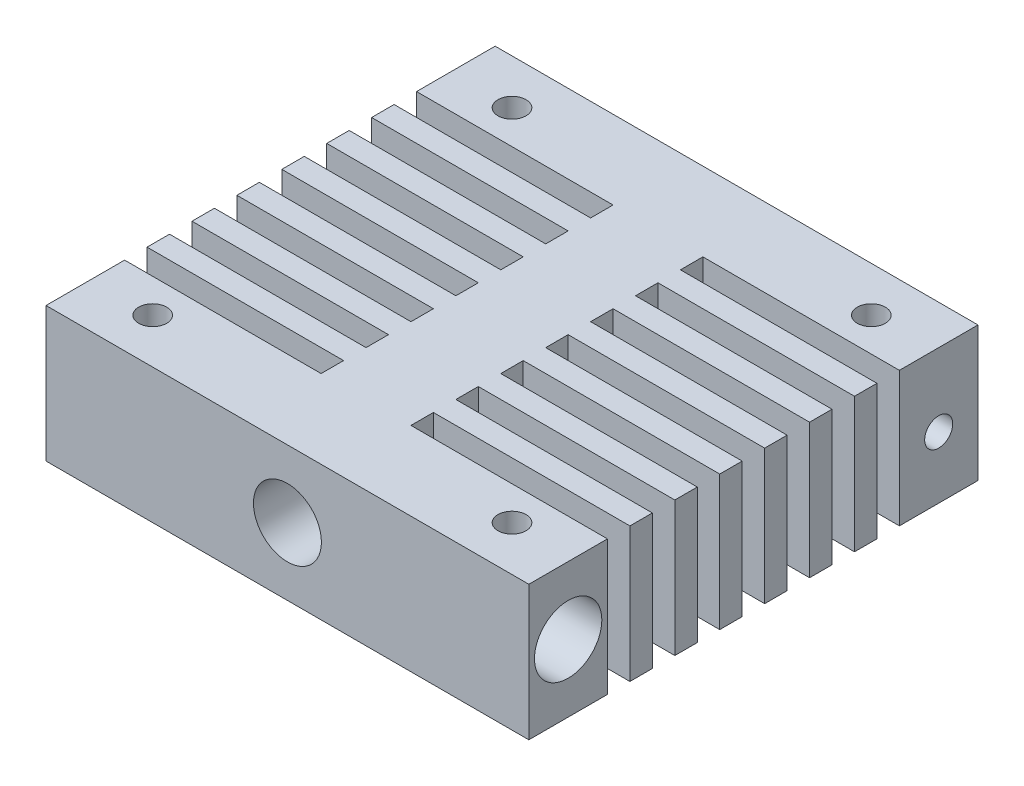
from build123d import *

# Parameters (mm, degrees)
SKETCH_1_W              = 43
SKETCH_1_H              = 40
EXTRUDE_1_DEPTH         = 2
SKETCH_3_W              = 43
SKETCH_3_H              = 40
EXTRUDE_3_DEPTH         = 10
SKETCH_4_R              = 3.025
CUT_EXTRUDE_1_DEPTH     = 20
CUT_EXTRUDE_2_REACH     = 48.971
SKETCH_5_R              = 2.025
HOLE_WIZARD_M6_1_D      = 5
HOLE_WIZARD_M6_1_DEPTH  = 8
SKETCH_8_W              = 17.5
SKETCH_8_H              = 2
CUT_EXTRUDE_3_DEPTH     = 12
HOLE_WIZARD_M3_1_D      = 2.5
HOLE_WIZARD_M3_2_D      = 2.5
HOLE_WIZARD_M3_2_DEPTH  = 4
HOLE_WIZARD_M3_3_D      = 2.5
HOLE_WIZARD_M3_3_DEPTH  = 4
SKETCH_16_R             = 3
CUT_EXTRUDE_4_DEPTH     = 13.5
HOLE_WIZARD_M3_4_REACH  = 39.607
HOLE_WIZARD_M3_4_BORE_R = 1.25


with BuildPart() as part:
    # 草图1 → 凸台-拉伸1 (new body)
    with BuildSketch(Plane(origin=(0, 0, 0), x_dir=(1, 0, 0), z_dir=(0, 1, 0))):
        Rectangle(SKETCH_1_W, SKETCH_1_H)
    extrude(amount=EXTRUDE_1_DEPTH)

    # 草图3 → 凸台-拉伸3 (add)
    with BuildSketch(Plane(origin=(0, 2, 0), x_dir=(1, 0, 0), z_dir=(0, 1, 0))):
        Rectangle(SKETCH_3_W, SKETCH_3_H)
    extrude(amount=EXTRUDE_3_DEPTH)

    # 草图4 → 切除-拉伸1 (cut)
    with BuildSketch(Plane.XY.offset(20)):
        with Locations((0, 6)):
            Circle(SKETCH_4_R)
    extrude(amount=-CUT_EXTRUDE_1_DEPTH, mode=Mode.SUBTRACT)

    # 草图5 → 切除-拉伸2 (cut, up to next)
    with BuildSketch(Plane(origin=(0, 0, -20), x_dir=(-1, 0, 0), z_dir=(0, 0, -1)), mode=Mode.PRIVATE) as cut_extrude_2_sk1:
        with Locations((0, 6)):
            Circle(SKETCH_5_R)
    cut_extrude_2_tool1 = extrude(cut_extrude_2_sk1.sketch, amount=-CUT_EXTRUDE_2_REACH, mode=Mode.PRIVATE) & part.part
    add(cut_extrude_2_tool1.solids().sort_by_distance((0, 6, -20))[0], mode=Mode.SUBTRACT)

    # M6 螺纹孔1
    with Locations(Plane(origin=(0, 0, -20), x_dir=(-1, 0, 0), z_dir=(0, 0, -1))):
        with Locations((0, 6)):
            Hole(HOLE_WIZARD_M6_1_D / 2, depth=HOLE_WIZARD_M6_1_DEPTH)

    # 草图8 → 切除-拉伸3 (cut)
    with BuildSketch(Plane(origin=(0, 12, 0), x_dir=(1, 0, 0), z_dir=(0, 1, 0))):
        with Locations((-12.75, -12)):
            Rectangle(SKETCH_8_W, SKETCH_8_H)
        with Locations((-12.75, -8)):
            Rectangle(SKETCH_8_W, SKETCH_8_H)
        with Locations((-12.75, -4)):
            Rectangle(SKETCH_8_W, SKETCH_8_H)
        with Locations((-12.75, 0)):
            Rectangle(SKETCH_8_W, SKETCH_8_H)
        with Locations((-12.75, 4)):
            Rectangle(SKETCH_8_W, SKETCH_8_H)
        with Locations((-12.75, 8)):
            Rectangle(SKETCH_8_W, SKETCH_8_H)
        with Locations((-12.75, 12)):
            Rectangle(SKETCH_8_W, SKETCH_8_H)
        with Locations((12.75, 12)):
            Rectangle(SKETCH_8_W, SKETCH_8_H)
        with Locations((12.75, 8)):
            Rectangle(SKETCH_8_W, SKETCH_8_H)
        with Locations((12.75, 4)):
            Rectangle(SKETCH_8_W, SKETCH_8_H)
        with Locations((12.75, 0)):
            Rectangle(SKETCH_8_W, SKETCH_8_H)
        with Locations((12.75, -4)):
            Rectangle(SKETCH_8_W, SKETCH_8_H)
        with Locations((12.75, -8)):
            Rectangle(SKETCH_8_W, SKETCH_8_H)
        with Locations((12.75, -12)):
            Rectangle(SKETCH_8_W, SKETCH_8_H)
    extrude(amount=-CUT_EXTRUDE_3_DEPTH, mode=Mode.SUBTRACT)

    # M3 螺纹孔1 (through all)
    with Locations(Plane(origin=(0, 12, 0), x_dir=(1, 0, 0), z_dir=(0, 1, 0))):
        with Locations((-16, 16), (16, 16), (-16, -16), (16, -16)):
            Hole(HOLE_WIZARD_M3_1_D / 2)

    # M3 螺纹孔2
    with Locations(Plane(origin=(21.5, 0, 0), x_dir=(0, 0, -1), z_dir=(1, 0, 0))):
        with Locations((16.5, 5.5)):
            Hole(HOLE_WIZARD_M3_2_D / 2, depth=HOLE_WIZARD_M3_2_DEPTH)

    # M3 螺纹孔3
    with Locations(Plane.ZY.offset(21.5)):
        with Locations((-16.5, 5.5), (16.5, 5.5)):
            Hole(HOLE_WIZARD_M3_3_D / 2, depth=HOLE_WIZARD_M3_3_DEPTH)

    # 草图16 → 切除-拉伸4 (cut)
    with BuildSketch(Plane(origin=(21.5, 0, 0), x_dir=(0, 0, -1), z_dir=(1, 0, 0))):
        with Locations((-16.5, 6)):
            Circle(SKETCH_16_R)
    extrude(amount=-CUT_EXTRUDE_4_DEPTH, mode=Mode.SUBTRACT)

    # M3 螺纹孔4 bore → M3 螺纹孔4 (cut, up to next)
    with BuildSketch(Plane(origin=(8, 0, 0), x_dir=(0, 0, -1), z_dir=(1, 0, 0)), mode=Mode.PRIVATE) as hole_wizard_m3_4_sk1:
        with Locations((-16.5, 6)):
            Circle(HOLE_WIZARD_M3_4_BORE_R)
    hole_wizard_m3_4_tool1 = extrude(hole_wizard_m3_4_sk1.sketch, amount=-HOLE_WIZARD_M3_4_REACH, mode=Mode.PRIVATE) & part.part
    add(hole_wizard_m3_4_tool1.solids().sort_by_distance((8, 6, 16.5))[0], mode=Mode.SUBTRACT)


solid = part.part
